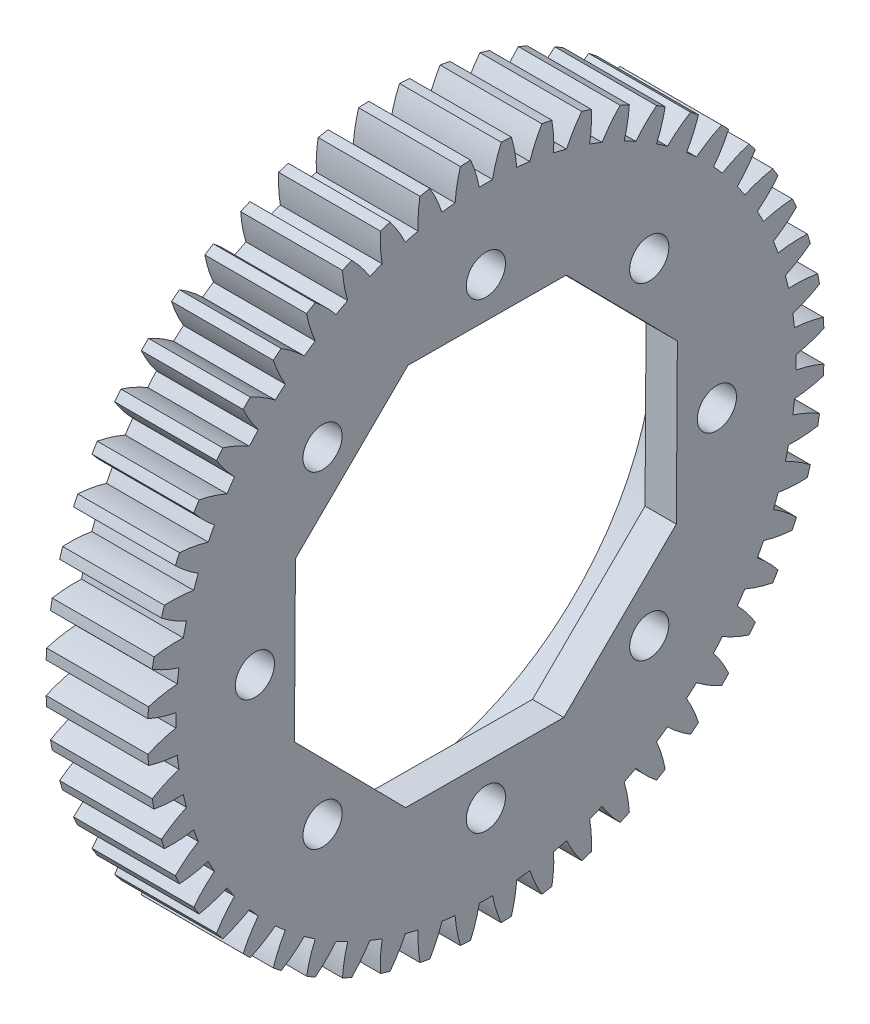
from build123d import *

# Parameters (mm, degrees)
CROQUIS1_W                                          = 6.5
CROQUIS1_H                                          = 21.6
CORTAR_EXTRUIR1_DEPTH                               = 7.5
CORTAR_EXTRUIR2_DEPTH                               = 7.5
CORTAR_EXTRUIR3_DEPTH                               = 7.5
CORTAR_EXTRUIR4_DEPTH                               = 7.5
CORTAR_EXTRUIR5_DEPTH                               = 7.5
CORTAR_EXTRUIR6_DEPTH                               = 7.5
CORTAR_EXTRUIR7_DEPTH                               = 7.5
CORTAR_EXTRUIR8_DEPTH                               = 7.5
CORTAR_EXTRUIR9_DEPTH                               = 7.5
CORTAR_EXTRUIR10_DEPTH                              = 7.5
CORTAR_EXTRUIR11_DEPTH                              = 7.5
CORTAR_EXTRUIR12_DEPTH                              = 7.5
CORTAR_EXTRUIR13_DEPTH                              = 7.5
CORTAR_EXTRUIR14_DEPTH                              = 7.5
CORTAR_EXTRUIR15_DEPTH                              = 7.5
CORTAR_EXTRUIR16_DEPTH                              = 7.5
CORTAR_EXTRUIR17_DEPTH                              = 7.5
CORTAR_EXTRUIR18_DEPTH                              = 7.5
CORTAR_EXTRUIR19_DEPTH                              = 7.5
CORTAR_EXTRUIR20_DEPTH                              = 7.5
CORTAR_EXTRUIR21_DEPTH                              = 7.5
CORTAR_EXTRUIR22_DEPTH                              = 7.5
CORTAR_EXTRUIR23_DEPTH                              = 7.5
CORTAR_EXTRUIR24_DEPTH                              = 7.5
CORTAR_EXTRUIR25_DEPTH                              = 7.5
CORTAR_EXTRUIR26_DEPTH                              = 7.5
CORTAR_EXTRUIR27_DEPTH                              = 7.5
CORTAR_EXTRUIR28_DEPTH                              = 7.5
CORTAR_EXTRUIR29_DEPTH                              = 7.5
CORTAR_EXTRUIR30_DEPTH                              = 7.5
CORTAR_EXTRUIR31_DEPTH                              = 7.5
CORTAR_EXTRUIR32_DEPTH                              = 7.5
CORTAR_EXTRUIR33_DEPTH                              = 7.5
CORTAR_EXTRUIR34_DEPTH                              = 7.5
CORTAR_EXTRUIR35_DEPTH                              = 7.5
CORTAR_EXTRUIR36_DEPTH                              = 7.5
CORTAR_EXTRUIR37_DEPTH                              = 7.5
CORTAR_EXTRUIR38_DEPTH                              = 7.5
CORTAR_EXTRUIR39_DEPTH                              = 7.5
CORTAR_EXTRUIR40_DEPTH                              = 7.5
CORTAR_EXTRUIR41_DEPTH                              = 7.5
CORTAR_EXTRUIR42_DEPTH                              = 7.5
CORTAR_EXTRUIR43_DEPTH                              = 7.5
CORTAR_EXTRUIR44_DEPTH                              = 7.5
CORTAR_EXTRUIR45_DEPTH                              = 7.5
CORTAR_EXTRUIR46_DEPTH                              = 7.5
CORTAR_EXTRUIR47_DEPTH                              = 7.5
CORTAR_EXTRUIR48_DEPTH                              = 7.5
CORTAR_EXTRUIR49_DEPTH                              = 7.5
CORTAR_EXTRUIR50_DEPTH                              = 7.5
CORTAR_EXTRUIR51_DEPTH                              = 7.5
CORTAR_EXTRUIR52_DEPTH                              = 7.5
REFRENTADO_PARA_TORNILLO_DE_FIJACI_N_DE_D           = 4
REFRENTADO_PARA_TORNILLO_DE_FIJACI_N_DE_DEPTH       = 6.5
REFRENTADO_PARA_TORNILLO_DE_FIJACI_N_DE_CBORE_D     = 34.6
REFRENTADO_PARA_TORNILLO_DE_FIJACI_N_DE_CBORE_DEPTH = 4.5
TALADRO_DE_MARGEN_PARA_21_D                         = 2.5
TALADRO_DE_MARGEN_PARA_21_DEPTH                     = 6.5
CORTAR_EXTRUIR54_DEPTH                              = 2.54


with BuildPart() as part:
    # Croquis1 → Revolución1 (revolve)
    with BuildSketch(Plane(origin=(0, 0, 0), x_dir=(-1, 0, 0), z_dir=(0, 0, -1))):
        with Locations((-3.25, 10.8)):
            Rectangle(CROQUIS1_W, CROQUIS1_H)
    revolve(axis=Axis((6.5, 0, 0), (-1, 0, 0)))

    # Croquis2 → Cortar-Extruir1 (cut, through all)
    with BuildSketch(Plane(origin=(6.5, 0, 0), x_dir=(0, 0, -1), z_dir=(1, 0, 0))):
        with BuildLine():
            ThreePointArc((-21.301862387, 3.576403059), (-21.442511681, 2.603592294), (-21.538758255, 1.625390062))
            ThreePointArc((-21.538758255, 1.625390062), (-20.629558037, 1.847190437), (-19.70120026, 1.965479412))
            ThreePointArc((-19.70120026, 1.965479412), (-19.654642998, 2.386505732), (-19.599089197, 2.806439675))
            ThreePointArc((-19.599089197, 2.806439675), (-20.472162179, 3.143461945), (-21.301862387, 3.576403059))
        make_face()
    extrude(amount=-CORTAR_EXTRUIR1_DEPTH, mode=Mode.SUBTRACT)

    # Croquis3 → Cortar-Extruir2 (cut, through all)
    with BuildSketch(Plane(origin=(6.5, 0, 0), x_dir=(0, 0, -1), z_dir=(1, 0, 0))):
        with BuildLine():
            ThreePointArc((-20.715460074, 6.11798283), (-20.972343256, 5.169218349), (-21.185797334, 4.209749555))
            ThreePointArc((-21.185797334, 4.209749555), (-20.256491129, 4.32034078), (-19.320643965, 4.32586613))
            ThreePointArc((-19.320643965, 4.32586613), (-19.223677043, 4.738210837), (-19.117910848, 5.148386718))
            ThreePointArc((-19.117910848, 5.148386718), (-19.9439946, 5.588189035), (-20.715460074, 6.11798283))
        make_face()
    extrude(amount=-CORTAR_EXTRUIR2_DEPTH, mode=Mode.SUBTRACT)

    # Croquis4 → Cortar-Extruir3 (cut, through all)
    with BuildSketch(Plane(origin=(6.5, 0, 0), x_dir=(0, 0, -1), z_dir=(1, 0, 0))):
        with BuildLine():
            ThreePointArc((-19.826979707, 8.570348634), (-20.196350842, 7.65946556), (-20.523899782, 6.73272142))
            ThreePointArc((-20.523899782, 6.73272142), (-19.588038966, 6.730490826), (-18.658349175, 6.623171979))
            ThreePointArc((-18.658349175, 6.623171979), (-18.512386589, 7.020822159), (-18.35795031, 7.41525869))
            ThreePointArc((-18.35795031, 7.41525869), (-19.124998669, 7.951427746), (-19.826979707, 8.570348634))
        make_face()
    extrude(amount=-CORTAR_EXTRUIR3_DEPTH, mode=Mode.SUBTRACT)

    # Croquis5 → Cortar-Extruir4 (cut, through all)
    with BuildSketch(Plane(origin=(6.5, 0, 0), x_dir=(0, 0, -1), z_dir=(1, 0, 0))):
        with BuildLine():
            ThreePointArc((-18.649377329, 10.897739456), (-19.125850154, 10.038020516), (-19.562717556, 9.157515046))
            ThreePointArc((-19.562717556, 9.157515046), (-18.633949087, 9.042495159), (-17.723973639, 8.823897067))
            ThreePointArc((-17.723973639, 8.823897067), (-17.531143852, 9.201054083), (-17.330289517, 9.573999491))
            ThreePointArc((-17.330289517, 9.573999491), (-18.027117192, 10.198716734), (-18.649377329, 10.897739456))
        make_face()
    extrude(amount=-CORTAR_EXTRUIR4_DEPTH, mode=Mode.SUBTRACT)

    # Croquis6 → Cortar-Extruir5 (cut, through all)
    with BuildSketch(Plane(origin=(6.5, 0, 0), x_dir=(0, 0, -1), z_dir=(1, 0, 0))):
        with BuildLine():
            ThreePointArc((-17.199825034, 13.066216698), (-17.776451503, 12.270198529), (-18.316266856, 11.448771482))
            ThreePointArc((-18.316266856, 11.448771482), (-17.408134271, 11.222639552), (-16.531142656, 10.895949866))
            ThreePointArc((-16.531142656, 10.895949866), (-16.294257561, 11.247113921), (-16.049914079, 11.593129822))
            ThreePointArc((-16.049914079, 11.593129822), (-16.666359753, 12.297285467), (-17.199825034, 13.066216698))
        make_face()
    extrude(amount=-CORTAR_EXTRUIR5_DEPTH, mode=Mode.SUBTRACT)

    # Croquis7 → Cortar-Extruir6 (cut, through all)
    with BuildSketch(Plane(origin=(6.5, 0, 0), x_dir=(0, 0, -1), z_dir=(1, 0, 0))):
        with BuildLine():
            ThreePointArc((-15.49946056, 15.044159077), (-16.16783216, 14.323449418), (-16.802723741, 13.573079049))
            ThreePointArc((-16.802723741, 13.573079049), (-15.928469657, 13.239132588), (-15.097250389, 12.80911518))
            ThreePointArc((-15.097250389, 12.80911518), (-14.819764303, 13.129165511), (-14.535494752, 13.443206214))
            ThreePointArc((-14.535494752, 13.443206214), (-15.06256926, 14.216532087), (-15.49946056, 15.044159077))
        make_face()
    extrude(amount=-CORTAR_EXTRUIR6_DEPTH, mode=Mode.SUBTRACT)

    # Croquis8 → Cortar-Extruir7 (cut, through all)
    with BuildSketch(Plane(origin=(6.5, 0, 0), x_dir=(0, 0, -1), z_dir=(1, 0, 0))):
        with BuildLine():
            ThreePointArc((-13.573079049, 16.802723741), (-14.323449418, 16.16783216), (-15.044159077, 15.49946056))
            ThreePointArc((-15.044159077, 15.49946056), (-14.216532087, 15.06256926), (-13.443206214, 14.535494752))
            ThreePointArc((-13.443206214, 14.535494752), (-13.129165511, 14.819764303), (-12.80911518, 15.097250389))
            ThreePointArc((-12.80911518, 15.097250389), (-13.239132588, 15.928469657), (-13.573079049, 16.802723741))
        make_face()
    extrude(amount=-CORTAR_EXTRUIR7_DEPTH, mode=Mode.SUBTRACT)

    # Croquis9 → Cortar-Extruir8 (cut, through all)
    with BuildSketch(Plane(origin=(6.5, 0, 0), x_dir=(0, 0, -1), z_dir=(1, 0, 0))):
        with BuildLine():
            ThreePointArc((-11.448771482, 18.316266856), (-12.270198529, 17.776451503), (-13.066216698, 17.199825034))
            ThreePointArc((-13.066216698, 17.199825034), (-12.297285467, 16.666359753), (-11.593129822, 16.049914079))
            ThreePointArc((-11.593129822, 16.049914079), (-11.247113921, 16.294257561), (-10.895949866, 16.531142656))
            ThreePointArc((-10.895949866, 16.531142656), (-11.222639552, 17.408134271), (-11.448771482, 18.316266856))
        make_face()
    extrude(amount=-CORTAR_EXTRUIR8_DEPTH, mode=Mode.SUBTRACT)

    # Croquis10 → Cortar-Extruir9 (cut, through all)
    with BuildSketch(Plane(origin=(6.5, 0, 0), x_dir=(0, 0, -1), z_dir=(1, 0, 0))):
        with BuildLine():
            ThreePointArc((-9.157515046, 19.562717556), (-10.038020516, 19.125850154), (-10.897739456, 18.649377329))
            ThreePointArc((-10.897739456, 18.649377329), (-10.198716734, 18.027117192), (-9.573999491, 17.330289517))
            ThreePointArc((-9.573999491, 17.330289517), (-9.201054083, 17.531143852), (-8.823897067, 17.723973639))
            ThreePointArc((-8.823897067, 17.723973639), (-9.042495159, 18.633949087), (-9.157515046, 19.562717556))
        make_face()
    extrude(amount=-CORTAR_EXTRUIR9_DEPTH, mode=Mode.SUBTRACT)

    # Croquis11 → Cortar-Extruir10 (cut, through all)
    with BuildSketch(Plane(origin=(6.5, 0, 0), x_dir=(0, 0, -1), z_dir=(1, 0, 0))):
        with BuildLine():
            ThreePointArc((-6.73272142, 20.523899782), (-7.65946556, 20.196350842), (-8.570348634, 19.826979707))
            ThreePointArc((-8.570348634, 19.826979707), (-7.951427746, 19.124998669), (-7.41525869, 18.35795031))
            ThreePointArc((-7.41525869, 18.35795031), (-7.020822159, 18.512386589), (-6.623171979, 18.658349175))
            ThreePointArc((-6.623171979, 18.658349175), (-6.730490826, 19.588038966), (-6.73272142, 20.523899782))
        make_face()
    extrude(amount=-CORTAR_EXTRUIR10_DEPTH, mode=Mode.SUBTRACT)

    # Croquis12 → Cortar-Extruir11 (cut, through all)
    with BuildSketch(Plane(origin=(6.5, 0, 0), x_dir=(0, 0, -1), z_dir=(1, 0, 0))):
        with BuildLine():
            ThreePointArc((-4.209749555, 21.185797334), (-5.169218349, 20.972343256), (-6.11798283, 20.715460074))
            ThreePointArc((-6.11798283, 20.715460074), (-5.588189035, 19.9439946), (-5.148386718, 19.117910848))
            ThreePointArc((-5.148386718, 19.117910848), (-4.738210837, 19.223677043), (-4.32586613, 19.320643965))
            ThreePointArc((-4.32586613, 19.320643965), (-4.32034078, 20.256491129), (-4.209749555, 21.185797334))
        make_face()
    extrude(amount=-CORTAR_EXTRUIR11_DEPTH, mode=Mode.SUBTRACT)

    # Croquis13 → Cortar-Extruir12 (cut, through all)
    with BuildSketch(Plane(origin=(6.5, 0, 0), x_dir=(0, 0, -1), z_dir=(1, 0, 0))):
        with BuildLine():
            ThreePointArc((-1.625390062, 21.538758255), (-2.603592294, 21.442511681), (-3.576403059, 21.301862387))
            ThreePointArc((-3.576403059, 21.301862387), (-3.143461945, 20.472162179), (-2.806439675, 19.599089197))
            ThreePointArc((-2.806439675, 19.599089197), (-2.386505732, 19.654642998), (-1.965479412, 19.70120026))
            ThreePointArc((-1.965479412, 19.70120026), (-1.847190437, 20.629558037), (-1.625390062, 21.538758255))
        make_face()
    extrude(amount=-CORTAR_EXTRUIR12_DEPTH, mode=Mode.SUBTRACT)

    # Croquis14 → Cortar-Extruir13 (cut, through all)
    with BuildSketch(Plane(origin=(6.5, 0, 0), x_dir=(0, 0, -1), z_dir=(1, 0, 0))):
        with BuildLine():
            ThreePointArc((0.982671279, 21.577635578), (0, 21.6), (-0.982671279, 21.577635578))
            ThreePointArc((-0.982671279, 21.577635578), (-0.652896102, 20.701799535), (-0.423568423, 19.794468692))
            ThreePointArc((-0.423568423, 19.794468692), (0, 19.799), (0.423568423, 19.794468692))
            ThreePointArc((0.423568423, 19.794468692), (0.652896102, 20.701799535), (0.982671279, 21.577635578))
        make_face()
    extrude(amount=-CORTAR_EXTRUIR13_DEPTH, mode=Mode.SUBTRACT)

    # Croquis15 → Cortar-Extruir14 (cut, through all)
    with BuildSketch(Plane(origin=(6.5, 0, 0), x_dir=(0, 0, -1), z_dir=(1, 0, 0))):
        with BuildLine():
            ThreePointArc((3.576403059, 21.301862387), (2.603592294, 21.442511681), (1.625390062, 21.538758255))
            ThreePointArc((1.625390062, 21.538758255), (1.847190437, 20.629558037), (1.965479412, 19.70120026))
            ThreePointArc((1.965479412, 19.70120026), (2.386505732, 19.654642998), (2.806439675, 19.599089197))
            ThreePointArc((2.806439675, 19.599089197), (3.143461945, 20.472162179), (3.576403059, 21.301862387))
        make_face()
    extrude(amount=-CORTAR_EXTRUIR14_DEPTH, mode=Mode.SUBTRACT)

    # Croquis16 → Cortar-Extruir15 (cut, through all)
    with BuildSketch(Plane(origin=(6.5, 0, 0), x_dir=(0, 0, -1), z_dir=(1, 0, 0))):
        with BuildLine():
            ThreePointArc((6.11798283, 20.715460074), (5.169218349, 20.972343256), (4.209749555, 21.185797334))
            ThreePointArc((4.209749555, 21.185797334), (4.32034078, 20.256491129), (4.32586613, 19.320643965))
            ThreePointArc((4.32586613, 19.320643965), (4.738210837, 19.223677043), (5.148386718, 19.117910848))
            ThreePointArc((5.148386718, 19.117910848), (5.588189035, 19.9439946), (6.11798283, 20.715460074))
        make_face()
    extrude(amount=-CORTAR_EXTRUIR15_DEPTH, mode=Mode.SUBTRACT)

    # Croquis17 → Cortar-Extruir16 (cut, through all)
    with BuildSketch(Plane(origin=(6.5, 0, 0), x_dir=(0, 0, -1), z_dir=(1, 0, 0))):
        with BuildLine():
            ThreePointArc((8.570348634, 19.826979707), (7.65946556, 20.196350842), (6.73272142, 20.523899782))
            ThreePointArc((6.73272142, 20.523899782), (6.730490826, 19.588038966), (6.623171979, 18.658349175))
            ThreePointArc((6.623171979, 18.658349175), (7.020822159, 18.512386589), (7.41525869, 18.35795031))
            ThreePointArc((7.41525869, 18.35795031), (7.951427746, 19.124998669), (8.570348634, 19.826979707))
        make_face()
    extrude(amount=-CORTAR_EXTRUIR16_DEPTH, mode=Mode.SUBTRACT)

    # Croquis18 → Cortar-Extruir17 (cut, through all)
    with BuildSketch(Plane(origin=(6.5, 0, 0), x_dir=(0, 0, -1), z_dir=(1, 0, 0))):
        with BuildLine():
            ThreePointArc((10.897739456, 18.649377329), (10.038020516, 19.125850154), (9.157515046, 19.562717556))
            ThreePointArc((9.157515046, 19.562717556), (9.042495159, 18.633949087), (8.823897067, 17.723973639))
            ThreePointArc((8.823897067, 17.723973639), (9.201054083, 17.531143852), (9.573999491, 17.330289517))
            ThreePointArc((9.573999491, 17.330289517), (10.198716734, 18.027117192), (10.897739456, 18.649377329))
        make_face()
    extrude(amount=-CORTAR_EXTRUIR17_DEPTH, mode=Mode.SUBTRACT)

    # Croquis19 → Cortar-Extruir18 (cut, through all)
    with BuildSketch(Plane(origin=(6.5, 0, 0), x_dir=(0, 0, -1), z_dir=(1, 0, 0))):
        with BuildLine():
            ThreePointArc((13.066216698, 17.199825034), (12.270198529, 17.776451503), (11.448771482, 18.316266856))
            ThreePointArc((11.448771482, 18.316266856), (11.222639552, 17.408134271), (10.895949866, 16.531142656))
            ThreePointArc((10.895949866, 16.531142656), (11.247113921, 16.294257561), (11.593129822, 16.049914079))
            ThreePointArc((11.593129822, 16.049914079), (12.297285467, 16.666359753), (13.066216698, 17.199825034))
        make_face()
    extrude(amount=-CORTAR_EXTRUIR18_DEPTH, mode=Mode.SUBTRACT)

    # Croquis20 → Cortar-Extruir19 (cut, through all)
    with BuildSketch(Plane(origin=(6.5, 0, 0), x_dir=(0, 0, -1), z_dir=(1, 0, 0))):
        with BuildLine():
            ThreePointArc((15.044159077, 15.49946056), (14.323449418, 16.16783216), (13.573079049, 16.802723741))
            ThreePointArc((13.573079049, 16.802723741), (13.239132588, 15.928469657), (12.80911518, 15.097250389))
            ThreePointArc((12.80911518, 15.097250389), (13.129165511, 14.819764303), (13.443206214, 14.535494752))
            ThreePointArc((13.443206214, 14.535494752), (14.216532087, 15.06256926), (15.044159077, 15.49946056))
        make_face()
    extrude(amount=-CORTAR_EXTRUIR19_DEPTH, mode=Mode.SUBTRACT)

    # Croquis21 → Cortar-Extruir20 (cut, through all)
    with BuildSketch(Plane(origin=(6.5, 0, 0), x_dir=(0, 0, -1), z_dir=(1, 0, 0))):
        with BuildLine():
            ThreePointArc((16.802723741, 13.573079049), (16.16783216, 14.323449418), (15.49946056, 15.044159077))
            ThreePointArc((15.49946056, 15.044159077), (15.06256926, 14.216532087), (14.535494752, 13.443206214))
            ThreePointArc((14.535494752, 13.443206214), (14.819764303, 13.129165511), (15.097250389, 12.80911518))
            ThreePointArc((15.097250389, 12.80911518), (15.928469657, 13.239132588), (16.802723741, 13.573079049))
        make_face()
    extrude(amount=-CORTAR_EXTRUIR20_DEPTH, mode=Mode.SUBTRACT)

    # Croquis22 → Cortar-Extruir21 (cut, through all)
    with BuildSketch(Plane(origin=(6.5, 0, 0), x_dir=(0, 0, -1), z_dir=(1, 0, 0))):
        with BuildLine():
            ThreePointArc((18.316266856, 11.448771482), (17.776451503, 12.270198529), (17.199825034, 13.066216698))
            ThreePointArc((17.199825034, 13.066216698), (16.666359753, 12.297285467), (16.049914079, 11.593129822))
            ThreePointArc((16.049914079, 11.593129822), (16.294257561, 11.247113921), (16.531142656, 10.895949866))
            ThreePointArc((16.531142656, 10.895949866), (17.408134271, 11.222639552), (18.316266856, 11.448771482))
        make_face()
    extrude(amount=-CORTAR_EXTRUIR21_DEPTH, mode=Mode.SUBTRACT)

    # Croquis23 → Cortar-Extruir22 (cut, through all)
    with BuildSketch(Plane(origin=(6.5, 0, 0), x_dir=(0, 0, -1), z_dir=(1, 0, 0))):
        with BuildLine():
            ThreePointArc((19.562717556, 9.157515046), (19.125850154, 10.038020516), (18.649377329, 10.897739456))
            ThreePointArc((18.649377329, 10.897739456), (18.027117192, 10.198716734), (17.330289517, 9.573999491))
            ThreePointArc((17.330289517, 9.573999491), (17.531143852, 9.201054083), (17.723973639, 8.823897067))
            ThreePointArc((17.723973639, 8.823897067), (18.633949087, 9.042495159), (19.562717556, 9.157515046))
        make_face()
    extrude(amount=-CORTAR_EXTRUIR22_DEPTH, mode=Mode.SUBTRACT)

    # Croquis24 → Cortar-Extruir23 (cut, through all)
    with BuildSketch(Plane(origin=(6.5, 0, 0), x_dir=(0, 0, -1), z_dir=(1, 0, 0))):
        with BuildLine():
            ThreePointArc((20.523899782, 6.73272142), (20.196350842, 7.65946556), (19.826979707, 8.570348634))
            ThreePointArc((19.826979707, 8.570348634), (19.124998669, 7.951427746), (18.35795031, 7.41525869))
            ThreePointArc((18.35795031, 7.41525869), (18.512386589, 7.020822159), (18.658349175, 6.623171979))
            ThreePointArc((18.658349175, 6.623171979), (19.588038966, 6.730490826), (20.523899782, 6.73272142))
        make_face()
    extrude(amount=-CORTAR_EXTRUIR23_DEPTH, mode=Mode.SUBTRACT)

    # Croquis25 → Cortar-Extruir24 (cut, through all)
    with BuildSketch(Plane(origin=(6.5, 0, 0), x_dir=(0, 0, -1), z_dir=(1, 0, 0))):
        with BuildLine():
            ThreePointArc((21.185797334, 4.209749555), (20.972343256, 5.169218349), (20.715460074, 6.11798283))
            ThreePointArc((20.715460074, 6.11798283), (19.9439946, 5.588189035), (19.117910848, 5.148386718))
            ThreePointArc((19.117910848, 5.148386718), (19.223677043, 4.738210837), (19.320643965, 4.32586613))
            ThreePointArc((19.320643965, 4.32586613), (20.256491129, 4.32034078), (21.185797334, 4.209749555))
        make_face()
    extrude(amount=-CORTAR_EXTRUIR24_DEPTH, mode=Mode.SUBTRACT)

    # Croquis26 → Cortar-Extruir25 (cut, through all)
    with BuildSketch(Plane(origin=(6.5, 0, 0), x_dir=(0, 0, -1), z_dir=(1, 0, 0))):
        with BuildLine():
            ThreePointArc((21.538758255, 1.625390062), (21.442511681, 2.603592294), (21.301862387, 3.576403059))
            ThreePointArc((21.301862387, 3.576403059), (20.472162179, 3.143461945), (19.599089197, 2.806439675))
            ThreePointArc((19.599089197, 2.806439675), (19.654642998, 2.386505732), (19.70120026, 1.965479412))
            ThreePointArc((19.70120026, 1.965479412), (20.629558037, 1.847190437), (21.538758255, 1.625390062))
        make_face()
    extrude(amount=-CORTAR_EXTRUIR25_DEPTH, mode=Mode.SUBTRACT)

    # Croquis27 → Cortar-Extruir26 (cut, through all)
    with BuildSketch(Plane(origin=(6.5, 0, 0), x_dir=(0, 0, -1), z_dir=(1, 0, 0))):
        with BuildLine():
            ThreePointArc((21.577635578, -0.982671279), (21.6, 0), (21.577635578, 0.982671279))
            ThreePointArc((21.577635578, 0.982671279), (20.701799535, 0.652896102), (19.794468692, 0.423568423))
            ThreePointArc((19.794468692, 0.423568423), (19.799, 0), (19.794468692, -0.423568423))
            ThreePointArc((19.794468692, -0.423568423), (20.701799535, -0.652896102), (21.577635578, -0.982671279))
        make_face()
    extrude(amount=-CORTAR_EXTRUIR26_DEPTH, mode=Mode.SUBTRACT)

    # Croquis28 → Cortar-Extruir27 (cut, through all)
    with BuildSketch(Plane(origin=(6.5, 0, 0), x_dir=(0, 0, -1), z_dir=(1, 0, 0))):
        with BuildLine():
            ThreePointArc((21.301862387, -3.576403059), (21.442511681, -2.603592294), (21.538758255, -1.625390062))
            ThreePointArc((21.538758255, -1.625390062), (20.629558037, -1.847190437), (19.70120026, -1.965479412))
            ThreePointArc((19.70120026, -1.965479412), (19.654642998, -2.386505732), (19.599089197, -2.806439675))
            ThreePointArc((19.599089197, -2.806439675), (20.472162179, -3.143461945), (21.301862387, -3.576403059))
        make_face()
    extrude(amount=-CORTAR_EXTRUIR27_DEPTH, mode=Mode.SUBTRACT)

    # Croquis29 → Cortar-Extruir28 (cut, through all)
    with BuildSketch(Plane(origin=(6.5, 0, 0), x_dir=(0, 0, -1), z_dir=(1, 0, 0))):
        with BuildLine():
            ThreePointArc((20.715460074, -6.11798283), (20.972343256, -5.169218349), (21.185797334, -4.209749555))
            ThreePointArc((21.185797334, -4.209749555), (20.256491129, -4.32034078), (19.320643965, -4.32586613))
            ThreePointArc((19.320643965, -4.32586613), (19.223677043, -4.738210837), (19.117910848, -5.148386718))
            ThreePointArc((19.117910848, -5.148386718), (19.9439946, -5.588189035), (20.715460074, -6.11798283))
        make_face()
    extrude(amount=-CORTAR_EXTRUIR28_DEPTH, mode=Mode.SUBTRACT)

    # Croquis30 → Cortar-Extruir29 (cut, through all)
    with BuildSketch(Plane(origin=(6.5, 0, 0), x_dir=(0, 0, -1), z_dir=(1, 0, 0))):
        with BuildLine():
            ThreePointArc((19.826979707, -8.570348634), (20.196350842, -7.65946556), (20.523899782, -6.73272142))
            ThreePointArc((20.523899782, -6.73272142), (19.588038966, -6.730490826), (18.658349175, -6.623171979))
            ThreePointArc((18.658349175, -6.623171979), (18.512386589, -7.020822159), (18.35795031, -7.41525869))
            ThreePointArc((18.35795031, -7.41525869), (19.124998669, -7.951427746), (19.826979707, -8.570348634))
        make_face()
    extrude(amount=-CORTAR_EXTRUIR29_DEPTH, mode=Mode.SUBTRACT)

    # Croquis31 → Cortar-Extruir30 (cut, through all)
    with BuildSketch(Plane(origin=(6.5, 0, 0), x_dir=(0, 0, -1), z_dir=(1, 0, 0))):
        with BuildLine():
            ThreePointArc((18.649377329, -10.897739456), (19.125850154, -10.038020516), (19.562717556, -9.157515046))
            ThreePointArc((19.562717556, -9.157515046), (18.633949087, -9.042495159), (17.723973639, -8.823897067))
            ThreePointArc((17.723973639, -8.823897067), (17.531143852, -9.201054083), (17.330289517, -9.573999491))
            ThreePointArc((17.330289517, -9.573999491), (18.027117192, -10.198716734), (18.649377329, -10.897739456))
        make_face()
    extrude(amount=-CORTAR_EXTRUIR30_DEPTH, mode=Mode.SUBTRACT)

    # Croquis32 → Cortar-Extruir31 (cut, through all)
    with BuildSketch(Plane(origin=(6.5, 0, 0), x_dir=(0, 0, -1), z_dir=(1, 0, 0))):
        with BuildLine():
            ThreePointArc((17.199825034, -13.066216698), (17.776451503, -12.270198529), (18.316266856, -11.448771482))
            ThreePointArc((18.316266856, -11.448771482), (17.408134271, -11.222639552), (16.531142656, -10.895949866))
            ThreePointArc((16.531142656, -10.895949866), (16.294257561, -11.247113921), (16.049914079, -11.593129822))
            ThreePointArc((16.049914079, -11.593129822), (16.666359753, -12.297285467), (17.199825034, -13.066216698))
        make_face()
    extrude(amount=-CORTAR_EXTRUIR31_DEPTH, mode=Mode.SUBTRACT)

    # Croquis33 → Cortar-Extruir32 (cut, through all)
    with BuildSketch(Plane(origin=(6.5, 0, 0), x_dir=(0, 0, -1), z_dir=(1, 0, 0))):
        with BuildLine():
            ThreePointArc((15.49946056, -15.044159077), (16.16783216, -14.323449418), (16.802723741, -13.573079049))
            ThreePointArc((16.802723741, -13.573079049), (15.928469657, -13.239132588), (15.097250389, -12.80911518))
            ThreePointArc((15.097250389, -12.80911518), (14.819764303, -13.129165511), (14.535494752, -13.443206214))
            ThreePointArc((14.535494752, -13.443206214), (15.06256926, -14.216532087), (15.49946056, -15.044159077))
        make_face()
    extrude(amount=-CORTAR_EXTRUIR32_DEPTH, mode=Mode.SUBTRACT)

    # Croquis34 → Cortar-Extruir33 (cut, through all)
    with BuildSketch(Plane(origin=(6.5, 0, 0), x_dir=(0, 0, -1), z_dir=(1, 0, 0))):
        with BuildLine():
            ThreePointArc((13.573079049, -16.802723741), (14.323449418, -16.16783216), (15.044159077, -15.49946056))
            ThreePointArc((15.044159077, -15.49946056), (14.216532087, -15.06256926), (13.443206214, -14.535494752))
            ThreePointArc((13.443206214, -14.535494752), (13.129165511, -14.819764303), (12.80911518, -15.097250389))
            ThreePointArc((12.80911518, -15.097250389), (13.239132588, -15.928469657), (13.573079049, -16.802723741))
        make_face()
    extrude(amount=-CORTAR_EXTRUIR33_DEPTH, mode=Mode.SUBTRACT)

    # Croquis35 → Cortar-Extruir34 (cut, through all)
    with BuildSketch(Plane(origin=(6.5, 0, 0), x_dir=(0, 0, -1), z_dir=(1, 0, 0))):
        with BuildLine():
            ThreePointArc((11.448771482, -18.316266856), (12.270198529, -17.776451503), (13.066216698, -17.199825034))
            ThreePointArc((13.066216698, -17.199825034), (12.297285467, -16.666359753), (11.593129822, -16.049914079))
            ThreePointArc((11.593129822, -16.049914079), (11.247113921, -16.294257561), (10.895949866, -16.531142656))
            ThreePointArc((10.895949866, -16.531142656), (11.222639552, -17.408134271), (11.448771482, -18.316266856))
        make_face()
    extrude(amount=-CORTAR_EXTRUIR34_DEPTH, mode=Mode.SUBTRACT)

    # Croquis36 → Cortar-Extruir35 (cut, through all)
    with BuildSketch(Plane(origin=(6.5, 0, 0), x_dir=(0, 0, -1), z_dir=(1, 0, 0))):
        with BuildLine():
            ThreePointArc((9.157515046, -19.562717556), (10.038020516, -19.125850154), (10.897739456, -18.649377329))
            ThreePointArc((10.897739456, -18.649377329), (10.198716734, -18.027117192), (9.573999491, -17.330289517))
            ThreePointArc((9.573999491, -17.330289517), (9.201054083, -17.531143852), (8.823897067, -17.723973639))
            ThreePointArc((8.823897067, -17.723973639), (9.042495159, -18.633949087), (9.157515046, -19.562717556))
        make_face()
    extrude(amount=-CORTAR_EXTRUIR35_DEPTH, mode=Mode.SUBTRACT)

    # Croquis37 → Cortar-Extruir36 (cut, through all)
    with BuildSketch(Plane(origin=(6.5, 0, 0), x_dir=(0, 0, -1), z_dir=(1, 0, 0))):
        with BuildLine():
            ThreePointArc((6.73272142, -20.523899782), (7.65946556, -20.196350842), (8.570348634, -19.826979707))
            ThreePointArc((8.570348634, -19.826979707), (7.951427746, -19.124998669), (7.41525869, -18.35795031))
            ThreePointArc((7.41525869, -18.35795031), (7.020822159, -18.512386589), (6.623171979, -18.658349175))
            ThreePointArc((6.623171979, -18.658349175), (6.730490826, -19.588038966), (6.73272142, -20.523899782))
        make_face()
    extrude(amount=-CORTAR_EXTRUIR36_DEPTH, mode=Mode.SUBTRACT)

    # Croquis38 → Cortar-Extruir37 (cut, through all)
    with BuildSketch(Plane(origin=(6.5, 0, 0), x_dir=(0, 0, -1), z_dir=(1, 0, 0))):
        with BuildLine():
            ThreePointArc((4.209749555, -21.185797334), (5.169218349, -20.972343256), (6.11798283, -20.715460074))
            ThreePointArc((6.11798283, -20.715460074), (5.588189035, -19.9439946), (5.148386718, -19.117910848))
            ThreePointArc((5.148386718, -19.117910848), (4.738210837, -19.223677043), (4.32586613, -19.320643965))
            ThreePointArc((4.32586613, -19.320643965), (4.32034078, -20.256491129), (4.209749555, -21.185797334))
        make_face()
    extrude(amount=-CORTAR_EXTRUIR37_DEPTH, mode=Mode.SUBTRACT)

    # Croquis39 → Cortar-Extruir38 (cut, through all)
    with BuildSketch(Plane(origin=(6.5, 0, 0), x_dir=(0, 0, -1), z_dir=(1, 0, 0))):
        with BuildLine():
            ThreePointArc((1.625390062, -21.538758255), (2.603592294, -21.442511681), (3.576403059, -21.301862387))
            ThreePointArc((3.576403059, -21.301862387), (3.143461945, -20.472162179), (2.806439675, -19.599089197))
            ThreePointArc((2.806439675, -19.599089197), (2.386505732, -19.654642998), (1.965479412, -19.70120026))
            ThreePointArc((1.965479412, -19.70120026), (1.847190437, -20.629558037), (1.625390062, -21.538758255))
        make_face()
    extrude(amount=-CORTAR_EXTRUIR38_DEPTH, mode=Mode.SUBTRACT)

    # Croquis40 → Cortar-Extruir39 (cut, through all)
    with BuildSketch(Plane(origin=(6.5, 0, 0), x_dir=(0, 0, -1), z_dir=(1, 0, 0))):
        with BuildLine():
            ThreePointArc((-0.982671279, -21.577635578), (0, -21.6), (0.982671279, -21.577635578))
            ThreePointArc((0.982671279, -21.577635578), (0.652896102, -20.701799535), (0.423568423, -19.794468692))
            ThreePointArc((0.423568423, -19.794468692), (0, -19.799), (-0.423568423, -19.794468692))
            ThreePointArc((-0.423568423, -19.794468692), (-0.652896102, -20.701799535), (-0.982671279, -21.577635578))
        make_face()
    extrude(amount=-CORTAR_EXTRUIR39_DEPTH, mode=Mode.SUBTRACT)

    # Croquis41 → Cortar-Extruir40 (cut, through all)
    with BuildSketch(Plane(origin=(6.5, 0, 0), x_dir=(0, 0, -1), z_dir=(1, 0, 0))):
        with BuildLine():
            ThreePointArc((-3.576403059, -21.301862387), (-2.603592294, -21.442511681), (-1.625390062, -21.538758255))
            ThreePointArc((-1.625390062, -21.538758255), (-1.847190437, -20.629558037), (-1.965479412, -19.70120026))
            ThreePointArc((-1.965479412, -19.70120026), (-2.386505732, -19.654642998), (-2.806439675, -19.599089197))
            ThreePointArc((-2.806439675, -19.599089197), (-3.143461945, -20.472162179), (-3.576403059, -21.301862387))
        make_face()
    extrude(amount=-CORTAR_EXTRUIR40_DEPTH, mode=Mode.SUBTRACT)

    # Croquis42 → Cortar-Extruir41 (cut, through all)
    with BuildSketch(Plane(origin=(6.5, 0, 0), x_dir=(0, 0, -1), z_dir=(1, 0, 0))):
        with BuildLine():
            ThreePointArc((-6.11798283, -20.715460074), (-5.169218349, -20.972343256), (-4.209749555, -21.185797334))
            ThreePointArc((-4.209749555, -21.185797334), (-4.32034078, -20.256491129), (-4.32586613, -19.320643965))
            ThreePointArc((-4.32586613, -19.320643965), (-4.738210837, -19.223677043), (-5.148386718, -19.117910848))
            ThreePointArc((-5.148386718, -19.117910848), (-5.588189035, -19.9439946), (-6.11798283, -20.715460074))
        make_face()
    extrude(amount=-CORTAR_EXTRUIR41_DEPTH, mode=Mode.SUBTRACT)

    # Croquis43 → Cortar-Extruir42 (cut, through all)
    with BuildSketch(Plane(origin=(6.5, 0, 0), x_dir=(0, 0, -1), z_dir=(1, 0, 0))):
        with BuildLine():
            ThreePointArc((-8.570348634, -19.826979707), (-7.65946556, -20.196350842), (-6.73272142, -20.523899782))
            ThreePointArc((-6.73272142, -20.523899782), (-6.730490826, -19.588038966), (-6.623171979, -18.658349175))
            ThreePointArc((-6.623171979, -18.658349175), (-7.020822159, -18.512386589), (-7.41525869, -18.35795031))
            ThreePointArc((-7.41525869, -18.35795031), (-7.951427746, -19.124998669), (-8.570348634, -19.826979707))
        make_face()
    extrude(amount=-CORTAR_EXTRUIR42_DEPTH, mode=Mode.SUBTRACT)

    # Croquis44 → Cortar-Extruir43 (cut, through all)
    with BuildSketch(Plane(origin=(6.5, 0, 0), x_dir=(0, 0, -1), z_dir=(1, 0, 0))):
        with BuildLine():
            ThreePointArc((-10.897739456, -18.649377329), (-10.038020516, -19.125850154), (-9.157515046, -19.562717556))
            ThreePointArc((-9.157515046, -19.562717556), (-9.042495159, -18.633949087), (-8.823897067, -17.723973639))
            ThreePointArc((-8.823897067, -17.723973639), (-9.201054083, -17.531143852), (-9.573999491, -17.330289517))
            ThreePointArc((-9.573999491, -17.330289517), (-10.198716734, -18.027117192), (-10.897739456, -18.649377329))
        make_face()
    extrude(amount=-CORTAR_EXTRUIR43_DEPTH, mode=Mode.SUBTRACT)

    # Croquis45 → Cortar-Extruir44 (cut, through all)
    with BuildSketch(Plane(origin=(6.5, 0, 0), x_dir=(0, 0, -1), z_dir=(1, 0, 0))):
        with BuildLine():
            ThreePointArc((-13.066216698, -17.199825034), (-12.270198529, -17.776451503), (-11.448771482, -18.316266856))
            ThreePointArc((-11.448771482, -18.316266856), (-11.222639552, -17.408134271), (-10.895949866, -16.531142656))
            ThreePointArc((-10.895949866, -16.531142656), (-11.247113921, -16.294257561), (-11.593129822, -16.049914079))
            ThreePointArc((-11.593129822, -16.049914079), (-12.297285467, -16.666359753), (-13.066216698, -17.199825034))
        make_face()
    extrude(amount=-CORTAR_EXTRUIR44_DEPTH, mode=Mode.SUBTRACT)

    # Croquis46 → Cortar-Extruir45 (cut, through all)
    with BuildSketch(Plane(origin=(6.5, 0, 0), x_dir=(0, 0, -1), z_dir=(1, 0, 0))):
        with BuildLine():
            ThreePointArc((-15.044159077, -15.49946056), (-14.323449418, -16.16783216), (-13.573079049, -16.802723741))
            ThreePointArc((-13.573079049, -16.802723741), (-13.239132588, -15.928469657), (-12.80911518, -15.097250389))
            ThreePointArc((-12.80911518, -15.097250389), (-13.129165511, -14.819764303), (-13.443206214, -14.535494752))
            ThreePointArc((-13.443206214, -14.535494752), (-14.216532087, -15.06256926), (-15.044159077, -15.49946056))
        make_face()
    extrude(amount=-CORTAR_EXTRUIR45_DEPTH, mode=Mode.SUBTRACT)

    # Croquis47 → Cortar-Extruir46 (cut, through all)
    with BuildSketch(Plane(origin=(6.5, 0, 0), x_dir=(0, 0, -1), z_dir=(1, 0, 0))):
        with BuildLine():
            ThreePointArc((-16.802723741, -13.573079049), (-16.16783216, -14.323449418), (-15.49946056, -15.044159077))
            ThreePointArc((-15.49946056, -15.044159077), (-15.06256926, -14.216532087), (-14.535494752, -13.443206214))
            ThreePointArc((-14.535494752, -13.443206214), (-14.819764303, -13.129165511), (-15.097250389, -12.80911518))
            ThreePointArc((-15.097250389, -12.80911518), (-15.928469657, -13.239132588), (-16.802723741, -13.573079049))
        make_face()
    extrude(amount=-CORTAR_EXTRUIR46_DEPTH, mode=Mode.SUBTRACT)

    # Croquis48 → Cortar-Extruir47 (cut, through all)
    with BuildSketch(Plane(origin=(6.5, 0, 0), x_dir=(0, 0, -1), z_dir=(1, 0, 0))):
        with BuildLine():
            ThreePointArc((-18.316266856, -11.448771482), (-17.776451503, -12.270198529), (-17.199825034, -13.066216698))
            ThreePointArc((-17.199825034, -13.066216698), (-16.666359753, -12.297285467), (-16.049914079, -11.593129822))
            ThreePointArc((-16.049914079, -11.593129822), (-16.294257561, -11.247113921), (-16.531142656, -10.895949866))
            ThreePointArc((-16.531142656, -10.895949866), (-17.408134271, -11.222639552), (-18.316266856, -11.448771482))
        make_face()
    extrude(amount=-CORTAR_EXTRUIR47_DEPTH, mode=Mode.SUBTRACT)

    # Croquis49 → Cortar-Extruir48 (cut, through all)
    with BuildSketch(Plane(origin=(6.5, 0, 0), x_dir=(0, 0, -1), z_dir=(1, 0, 0))):
        with BuildLine():
            ThreePointArc((-19.562717556, -9.157515046), (-19.125850154, -10.038020516), (-18.649377329, -10.897739456))
            ThreePointArc((-18.649377329, -10.897739456), (-18.027117192, -10.198716734), (-17.330289517, -9.573999491))
            ThreePointArc((-17.330289517, -9.573999491), (-17.531143852, -9.201054083), (-17.723973639, -8.823897067))
            ThreePointArc((-17.723973639, -8.823897067), (-18.633949087, -9.042495159), (-19.562717556, -9.157515046))
        make_face()
    extrude(amount=-CORTAR_EXTRUIR48_DEPTH, mode=Mode.SUBTRACT)

    # Croquis50 → Cortar-Extruir49 (cut, through all)
    with BuildSketch(Plane(origin=(6.5, 0, 0), x_dir=(0, 0, -1), z_dir=(1, 0, 0))):
        with BuildLine():
            ThreePointArc((-20.523899782, -6.73272142), (-20.196350842, -7.65946556), (-19.826979707, -8.570348634))
            ThreePointArc((-19.826979707, -8.570348634), (-19.124998669, -7.951427746), (-18.35795031, -7.41525869))
            ThreePointArc((-18.35795031, -7.41525869), (-18.512386589, -7.020822159), (-18.658349175, -6.623171979))
            ThreePointArc((-18.658349175, -6.623171979), (-19.588038966, -6.730490826), (-20.523899782, -6.73272142))
        make_face()
    extrude(amount=-CORTAR_EXTRUIR49_DEPTH, mode=Mode.SUBTRACT)

    # Croquis51 → Cortar-Extruir50 (cut, through all)
    with BuildSketch(Plane(origin=(6.5, 0, 0), x_dir=(0, 0, -1), z_dir=(1, 0, 0))):
        with BuildLine():
            ThreePointArc((-21.185797334, -4.209749555), (-20.972343256, -5.169218349), (-20.715460074, -6.11798283))
            ThreePointArc((-20.715460074, -6.11798283), (-19.9439946, -5.588189035), (-19.117910848, -5.148386718))
            ThreePointArc((-19.117910848, -5.148386718), (-19.223677043, -4.738210837), (-19.320643965, -4.32586613))
            ThreePointArc((-19.320643965, -4.32586613), (-20.256491129, -4.32034078), (-21.185797334, -4.209749555))
        make_face()
    extrude(amount=-CORTAR_EXTRUIR50_DEPTH, mode=Mode.SUBTRACT)

    # Croquis52 → Cortar-Extruir51 (cut, through all)
    with BuildSketch(Plane(origin=(6.5, 0, 0), x_dir=(0, 0, -1), z_dir=(1, 0, 0))):
        with BuildLine():
            ThreePointArc((-21.538758255, -1.625390062), (-21.442511681, -2.603592294), (-21.301862387, -3.576403059))
            ThreePointArc((-21.301862387, -3.576403059), (-20.472162179, -3.143461945), (-19.599089197, -2.806439675))
            ThreePointArc((-19.599089197, -2.806439675), (-19.654642998, -2.386505732), (-19.70120026, -1.965479412))
            ThreePointArc((-19.70120026, -1.965479412), (-20.629558037, -1.847190437), (-21.538758255, -1.625390062))
        make_face()
    extrude(amount=-CORTAR_EXTRUIR51_DEPTH, mode=Mode.SUBTRACT)

    # Croquis53 → Cortar-Extruir52 (cut, through all)
    with BuildSketch(Plane(origin=(6.5, 0, 0), x_dir=(0, 0, -1), z_dir=(1, 0, 0))):
        with BuildLine():
            ThreePointArc((-21.577635578, 0.982671279), (-21.6, 0), (-21.577635578, -0.982671279))
            ThreePointArc((-21.577635578, -0.982671279), (-20.701799535, -0.652896102), (-19.794468692, -0.423568423))
            ThreePointArc((-19.794468692, -0.423568423), (-19.799, 0), (-19.794468692, 0.423568423))
            ThreePointArc((-19.794468692, 0.423568423), (-20.701799535, 0.652896102), (-21.577635578, 0.982671279))
        make_face()
    extrude(amount=-CORTAR_EXTRUIR52_DEPTH, mode=Mode.SUBTRACT)

    # Refrentado para tornillo de fijación de #61
    with Locations(Plane.ZY):
        with Locations((0, 0)):
            CounterBoreHole(REFRENTADO_PARA_TORNILLO_DE_FIJACI_N_DE_D / 2, REFRENTADO_PARA_TORNILLO_DE_FIJACI_N_DE_CBORE_D / 2, REFRENTADO_PARA_TORNILLO_DE_FIJACI_N_DE_CBORE_DEPTH, depth=REFRENTADO_PARA_TORNILLO_DE_FIJACI_N_DE_DEPTH)

    # Taladro de margen para #21
    with Locations(Plane(origin=(6.5, 0, 0), x_dir=(0, 0, -1), z_dir=(1, 0, 0))):
        with Locations((14.75, 0), (10.429825023, -10.429825023), (0, -14.75), (-10.429825023, -10.429825023), (-14.75, 0), (-10.429825023, 10.429825023), (0, 14.75), (10.429825023, 10.429825023)):
            Hole(TALADRO_DE_MARGEN_PARA_21_D / 2, depth=TALADRO_DE_MARGEN_PARA_21_DEPTH)

    # Croquis58 → Cortar-Extruir54 (cut)
    with BuildSketch(Plane(origin=(6.5, 0, 0), x_dir=(0, 0, -1), z_dir=(1, 0, 0))):
        Polygon((12.22338232, 4.973652116), (5.126333389, 12.160139666), (-4.973652116, 12.22338232), (-12.160139666, 5.126333389), (-12.22338232, -4.973652116), (-5.126333389, -12.160139666), (4.973652116, -12.22338232), (12.160139666, -5.126333389), align=None)
    extrude(amount=-CORTAR_EXTRUIR54_DEPTH, mode=Mode.SUBTRACT)


solid = part.part
